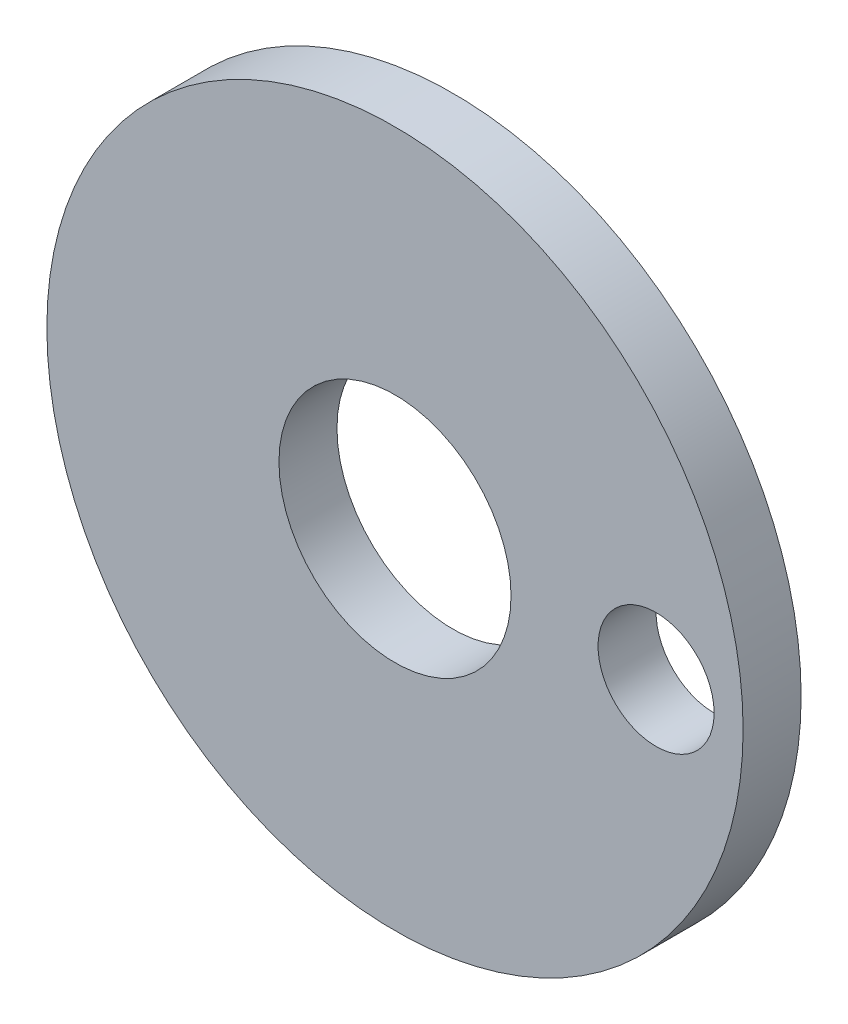
from build123d import *

# Parameters (mm, degrees)
SKETCH1_R           = 6
SKETCH1_R_2         = 2
SKETCH1_R_3         = 1
BOSS_EXTRUDE1_DEPTH = 1


with BuildPart() as part:
    # Sketch1 → Boss-Extrude1 (new body)
    with BuildSketch(Plane.XY):
        Circle(SKETCH1_R)
        Circle(SKETCH1_R_2, mode=Mode.SUBTRACT)
        with Locations((4.5, 0)):
            Circle(SKETCH1_R_3, mode=Mode.SUBTRACT)
    extrude(amount=BOSS_EXTRUDE1_DEPTH)


solid = part.part
